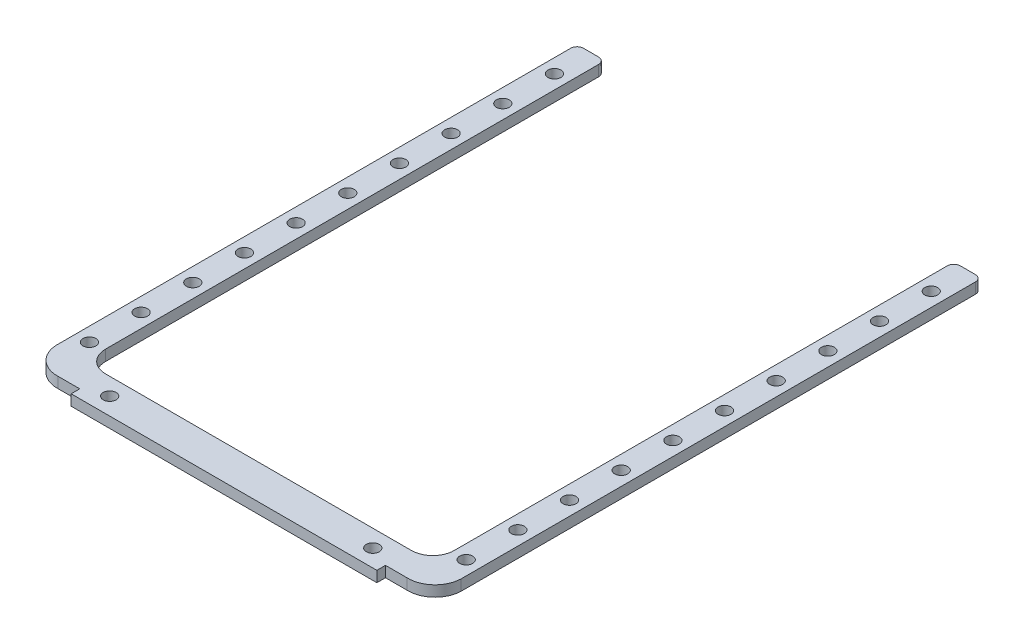
from build123d import *

# Parameters (mm, degrees)
BOSS_EXTRUDE1_DEPTH = 2.5
SKETCH2_R           = 1.5
CUT_EXTRUDE1_DEPTH  = 2.5
FILLET1_R           = 1.5


with BuildPart() as part:
    # Sketch1 → Boss-Extrude1 (new body)
    with BuildSketch(Plane(origin=(0, 0, 0), x_dir=(1, 0, 0), z_dir=(0, 1, 0))):
        with BuildLine():
            Line((-233.299741314, 67.325465398), (-233.299741314, -21.174534602))
            ThreePointArc((-233.299741314, -21.174534602), (-231.292382001, -25.52072868), (-226.799741314, -27.174534602))
            Line((-226.799741314, -27.174534602), (-221.799741314, -27.174534602))
            Line((-221.799741314, -27.174534602), (-221.799741314, -29.174534602))
            Line((-221.799741314, -29.174534602), (-150.799741314, -29.174534602))
            Line((-150.799741314, -29.174534602), (-150.799741314, -27.174534602))
            Line((-150.799741314, -27.174534602), (-145.799741314, -27.174534602))
            ThreePointArc((-145.799741314, -27.174534602), (-141.307100627, -25.52072868), (-139.299741314, -21.174534602))
            Line((-139.299741314, -21.174534602), (-139.299741314, 67.325465398))
            Line((-139.299741314, 67.325465398), (-139.299741314, 99.825465398))
            Line((-139.299741314, 99.825465398), (-145.799741314, 99.825465398))
            Line((-145.799741314, 99.825465398), (-145.799741314, 67.325465398))
            Line((-145.799741314, 67.325465398), (-145.799741314, -16.174534602))
            ThreePointArc((-145.799741314, -16.174534602), (-147.264207408, -19.710068508), (-150.799741314, -21.174534602))
            Line((-150.799741314, -21.174534602), (-221.799741314, -21.174534602))
            ThreePointArc((-221.799741314, -21.174534602), (-225.33527522, -19.710068508), (-226.799741314, -16.174534602))
            Line((-226.799741314, -16.174534602), (-226.799741314, 67.325465398))
            Line((-226.799741314, 67.325465398), (-226.799741314, 99.825465398))
            Line((-226.799741314, 99.825465398), (-233.299741314, 99.825465398))
            Line((-233.299741314, 99.825465398), (-233.299741314, 67.325465398))
        make_face()
    extrude(amount=BOSS_EXTRUDE1_DEPTH)

    # Sketch2 → Cut-Extrude1 (cut)
    with BuildSketch(Plane(origin=(0, 2.5, 0), x_dir=(1, 0, 0), z_dir=(0, 1, 0))):
        with Locations((-230.049741314, 7.325465398)):
            Circle(SKETCH2_R)
        with Locations((-142.549741314, 7.325465398)):
            Circle(SKETCH2_R)
        with Locations((-230.049741314, 31.325465398)):
            Circle(SKETCH2_R)
        with Locations((-230.049741314, 55.325465398)):
            Circle(SKETCH2_R)
        with Locations((-230.049741314, 43.325465398)):
            Circle(SKETCH2_R)
        with Locations((-230.049741314, 19.325465398)):
            Circle(SKETCH2_R)
        with Locations((-230.049741314, -4.674534602)):
            Circle(SKETCH2_R)
        with Locations((-142.549741314, -4.674534602)):
            Circle(SKETCH2_R)
        with Locations((-142.549741314, 19.325465398)):
            Circle(SKETCH2_R)
        with Locations((-142.549741314, 31.325465398)):
            Circle(SKETCH2_R)
        with Locations((-142.549741314, 43.325465398)):
            Circle(SKETCH2_R)
        with Locations((-142.549741314, 55.325465398)):
            Circle(SKETCH2_R)
        with Locations((-230.049741314, -16.674534602)):
            Circle(SKETCH2_R)
        with Locations((-142.549741314, -16.674534602)):
            Circle(SKETCH2_R)
        with Locations((-216.854480823, -25.174534602)):
            Circle(SKETCH2_R)
        with Locations((-155.745001805, -25.174534602)):
            Circle(SKETCH2_R)
        with Locations((-230.049741314, 67.325465398)):
            Circle(SKETCH2_R)
        with Locations((-142.549741314, 67.325465398)):
            Circle(SKETCH2_R)
        with Locations((-230.049741314, 79.325465398)):
            Circle(SKETCH2_R)
        with Locations((-142.549741314, 79.325465398)):
            Circle(SKETCH2_R)
        with Locations((-230.049741314, 91.325465398)):
            Circle(SKETCH2_R)
        with Locations((-142.549741314, 91.325465398)):
            Circle(SKETCH2_R)
    extrude(amount=-CUT_EXTRUDE1_DEPTH, mode=Mode.SUBTRACT)

    # Fillet1
    fillet1_edges = [part.edges().sort_by_distance(p)[0] for p in [
        (-145.799741314, 1.25, -99.825465398),
        (-139.299741314, 1.25, -99.825465398),
        (-233.299741314, 1.25, -99.825465398),
        (-226.799741314, 1.25, -99.825465398),
    ]]
    fillet(fillet1_edges, radius=FILLET1_R)


solid = part.part
